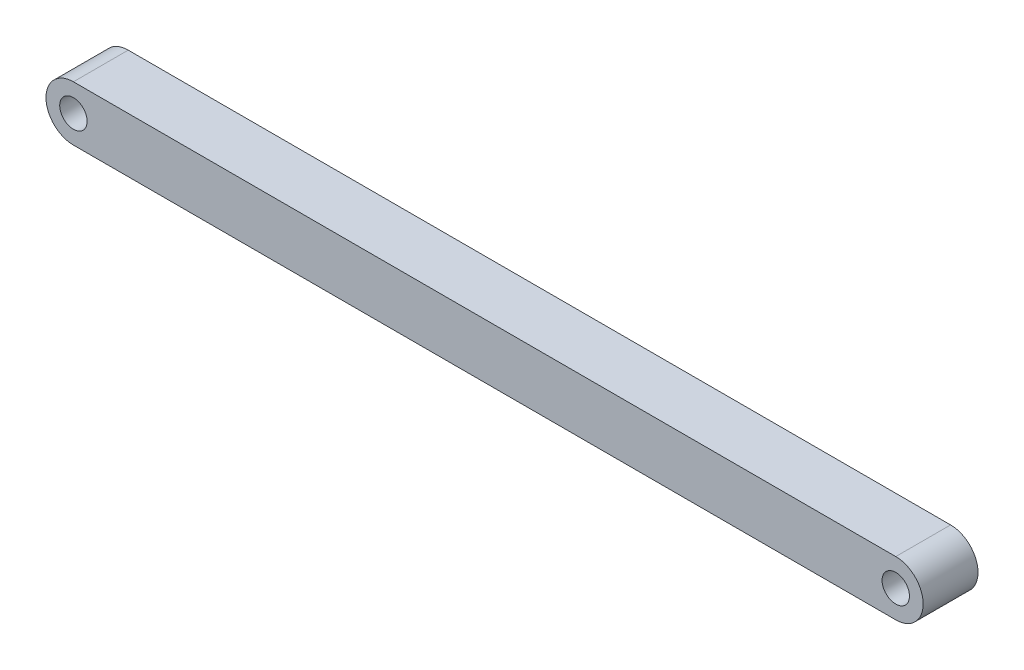
from build123d import *

# Parameters (mm, degrees)
SKETCH1_R           = 2.5
BOSS_EXTRUDE1_DEPTH = 5


with BuildPart() as part:
    # Sketch1 → Boss-Extrude1 (new, symmetric)
    with BuildSketch(Plane.XY):
        with BuildLine():
            Line((0, 5), (150, 5))
            ThreePointArc((150, 5), (155, 0), (150, -5))
            Line((150, -5), (0, -5))
            ThreePointArc((0, -5), (-5, 0), (0, 5))
        make_face()
        Circle(SKETCH1_R, mode=Mode.SUBTRACT)
        with Locations((150, 0)):
            Circle(SKETCH1_R, mode=Mode.SUBTRACT)
    extrude(amount=BOSS_EXTRUDE1_DEPTH, both=True)


solid = part.part
